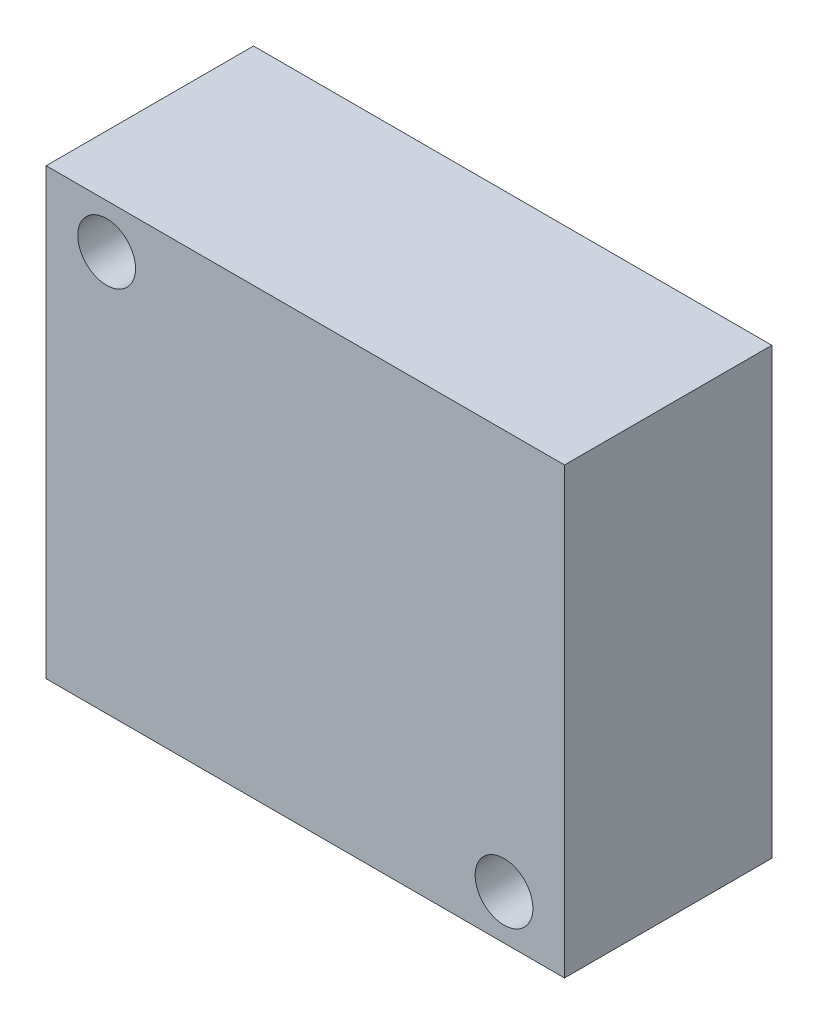
from build123d import *

# Parameters (mm, degrees)
ESQUISSE1_W        = 35
ESQUISSE1_H        = 30
BOSS_EXTRU_1_DEPTH = 14
D_GAGEMENT_M3_51_D = 3.9


with BuildPart() as part:
    # Esquisse1 → Boss.-Extru.1 (new body)
    with BuildSketch(Plane.XY):
        Rectangle(ESQUISSE1_W, ESQUISSE1_H)
    extrude(amount=BOSS_EXTRU_1_DEPTH)

    # Dégagement M3.51 (through all)
    with Locations(Plane.XY.offset(14)):
        with Locations((-13.416407865, 12), (13.416407865, -12)):
            Hole(D_GAGEMENT_M3_51_D / 2)


solid = part.part
